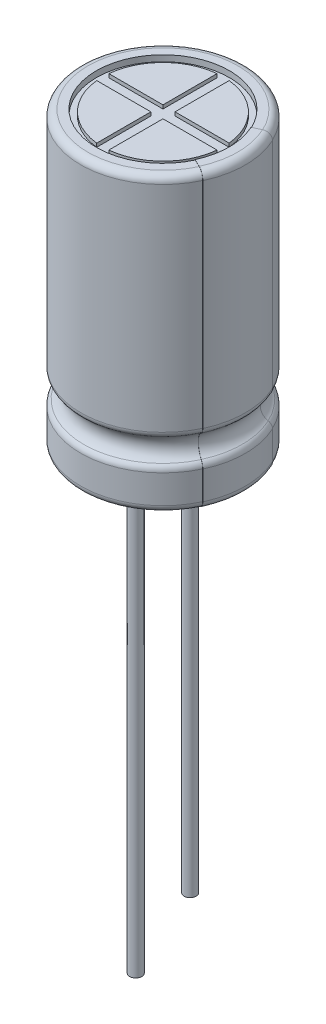
from build123d import *

# Parameters (mm, degrees)
BOSS_EXTRUDE1_DEPTH      = 0.15
BOSS_EXTRUDE1_2_DEPTH    = 0.15
BOSS_EXTRUDE1_3_DEPTH    = 0.15
BOSS_EXTRUDE1_4_DEPTH    = 0.15
SKETCH3_R                = 1.8
SKETCH3_RX               = 1.67
SKETCH3_RY               = 0.9
BOSS_EXTRUDE2_DEPTH      = 0.6
REVOLVE3_ANGLE           = 25
REVOLVE3_OTHER_WAY_ANGLE = 25
SKETCH7_R                = 0.25
BOSS_EXTRUDE3_DEPTH      = 19.6
SKETCH7_4_R              = 0.25
BOSS_EXTRUDE4_DEPTH      = 15.6


with BuildPart() as part:
    # Sketch1 → Revolve1 (revolve)
    with BuildSketch(Plane.XY, mode=Mode.PRIVATE) as revolve1_sk:
        with BuildLine():
            Line((0, 0.6), (2.8, 0.6))
            Line((2.8, 0.6), (2.8, 0.4))
            Line((2.8, 0.4), (3.1, 0.4))
            ThreePointArc((3.1, 0.4), (3.312132034, 0.487867966), (3.4, 0.7))
            Line((3.4, 0.7), (3.4, 1.873479579))
            ThreePointArc((3.4, 1.873479579), (3.365540419, 2.013080031), (3.270078093, 2.120609995))
            ThreePointArc((3.270078093, 2.120609995), (3.0180522, 2.6), (3.270078093, 3.079390005))
            ThreePointArc((3.270078093, 3.079390005), (3.365540419, 3.186919969), (3.4, 3.326520421))
            Line((3.4, 3.326520421), (3.4, 12.2))
            ThreePointArc((3.4, 12.2), (3.312132034, 12.412132034), (3.1, 12.5))
            Line((3.1, 12.5), (2.75, 12.5))
            Line((2.75, 12.5), (2.75, 12.25))
            Line((2.75, 12.25), (0, 12.25))
            Line((0, 12.25), (0, 0.6))
        make_face()
    revolve(revolve1_sk.sketch.rotate(Axis((0, 12.25, 0), (0, -1, 0)), 180), axis=Axis((0, 12.25, 0), (0, -1, 0)))



with BuildPart() as body_2:
    # Sketch2 → Boss-Extrude1 (new body)
    with BuildSketch(Plane(origin=(0, 12.25, 0), x_dir=(1, 0, 0), z_dir=(0, 1, 0))):
        with BuildLine():
            Line((-0.25, 0.25), (-0.25, 2.487468593))
            ThreePointArc((-0.25, 2.487468593), (-1.767766953, 1.767766953), (-2.487468593, 0.25))
            Line((-2.487468593, 0.25), (-0.25, 0.25))
        make_face()
    extrude(amount=BOSS_EXTRUDE1_DEPTH)


with BuildPart() as body_3:
    # Sketch2 → Boss-Extrude1 2 (new body)
    with BuildSketch(Plane(origin=(0, 12.25, 0), x_dir=(1, 0, 0), z_dir=(0, 1, 0))):
        with BuildLine():
            Line((0.25, -2.487468593), (0.25, -0.25))
            Line((0.25, -0.25), (2.487468593, -0.25))
            ThreePointArc((2.487468593, -0.25), (1.767766953, -1.767766953), (0.25, -2.487468593))
        make_face()
    extrude(amount=BOSS_EXTRUDE1_2_DEPTH)


with BuildPart() as body_4:
    # Sketch2 → Boss-Extrude1 3 (new body)
    with BuildSketch(Plane(origin=(0, 12.25, 0), x_dir=(1, 0, 0), z_dir=(0, 1, 0))):
        with BuildLine():
            Line((-0.25, -2.487468593), (-0.25, -0.25))
            Line((-0.25, -0.25), (-2.487468593, -0.25))
            ThreePointArc((-2.487468593, -0.25), (-1.767766953, -1.767766953), (-0.25, -2.487468593))
        make_face()
    extrude(amount=BOSS_EXTRUDE1_3_DEPTH)


with BuildPart() as body_5:
    # Sketch2 → Boss-Extrude1 4 (new body)
    with BuildSketch(Plane(origin=(0, 12.25, 0), x_dir=(1, 0, 0), z_dir=(0, 1, 0))):
        with BuildLine():
            Line((0.25, 0.25), (0.25, 2.487468593))
            ThreePointArc((0.25, 2.487468593), (1.767766953, 1.767766953), (2.487468593, 0.25))
            Line((2.487468593, 0.25), (0.25, 0.25))
        make_face()
    extrude(amount=BOSS_EXTRUDE1_4_DEPTH)


with BuildPart() as body_6:
    # Sketch3 → Boss-Extrude2 (new body)
    with BuildSketch(Plane.XZ.offset(-0.6)):
        Circle(SKETCH3_R)
        with Locations(Location((0, 0), (0, 0, 180))):
            Ellipse(SKETCH3_RX, SKETCH3_RY, mode=Mode.SUBTRACT)
    extrude(amount=BOSS_EXTRUDE2_DEPTH)


with BuildPart() as body_7:
    # Sketch5 → Revolve3 (revolve)
    with BuildSketch(Plane.XY):
        with BuildLine():
            Line((3.41, 12.2), (3.41, 3.326520421))
            ThreePointArc((3.41, 3.326520421), (3.374391766, 3.182266621), (3.275747363, 3.071152325))
            ThreePointArc((3.275747363, 3.071152325), (3.0280522, 2.6), (3.275747363, 2.128847675))
            ThreePointArc((3.275747363, 2.128847675), (3.374391766, 2.017733379), (3.41, 1.873479579))
            Line((3.41, 1.873479579), (3.41, 0.7))
            ThreePointArc((3.41, 0.7), (3.319203102, 0.480796898), (3.1, 0.39))
            Line((3.1, 0.39), (2.790041237, 0.39))
            Line((2.790041237, 0.39), (2.739958592, 12.51))
            Line((2.739958592, 12.51), (3.1, 12.51))
            ThreePointArc((3.1, 12.51), (3.319203102, 12.419203102), (3.41, 12.2))
        make_face()
        with BuildLine():
            Line((2.75, 12.5), (3.1, 12.5))
            ThreePointArc((3.1, 12.5), (3.312132034, 12.412132034), (3.4, 12.2))
            Line((3.4, 12.2), (3.4, 3.326520421))
            ThreePointArc((3.4, 3.326520421), (3.365540419, 3.186919969), (3.270078093, 3.079390005))
            ThreePointArc((3.270078093, 3.079390005), (3.0180522, 2.6), (3.270078093, 2.120609995))
            ThreePointArc((3.270078093, 2.120609995), (3.365540419, 2.013080031), (3.4, 1.873479579))
            Line((3.4, 1.873479579), (3.4, 0.7))
            ThreePointArc((3.4, 0.7), (3.312132034, 0.487867966), (3.1, 0.4))
            Line((3.1, 0.4), (2.8, 0.4))
            Line((2.8, 0.4), (2.75, 12.5))
        make_face(mode=Mode.SUBTRACT)
    revolve(axis=Axis((0, 0, 0), (0, 1, 0)), revolution_arc=REVOLVE3_ANGLE)

    # Sketch5 → Revolve3 other way (revolve)
    with BuildSketch(Plane.XY):
        with BuildLine():
            Line((3.41, 12.2), (3.41, 3.326520421))
            ThreePointArc((3.41, 3.326520421), (3.374391766, 3.182266621), (3.275747363, 3.071152325))
            ThreePointArc((3.275747363, 3.071152325), (3.0280522, 2.6), (3.275747363, 2.128847675))
            ThreePointArc((3.275747363, 2.128847675), (3.374391766, 2.017733379), (3.41, 1.873479579))
            Line((3.41, 1.873479579), (3.41, 0.7))
            ThreePointArc((3.41, 0.7), (3.319203102, 0.480796898), (3.1, 0.39))
            Line((3.1, 0.39), (2.790041237, 0.39))
            Line((2.790041237, 0.39), (2.739958592, 12.51))
            Line((2.739958592, 12.51), (3.1, 12.51))
            ThreePointArc((3.1, 12.51), (3.319203102, 12.419203102), (3.41, 12.2))
        make_face()
        with BuildLine():
            Line((2.75, 12.5), (3.1, 12.5))
            ThreePointArc((3.1, 12.5), (3.312132034, 12.412132034), (3.4, 12.2))
            Line((3.4, 12.2), (3.4, 3.326520421))
            ThreePointArc((3.4, 3.326520421), (3.365540419, 3.186919969), (3.270078093, 3.079390005))
            ThreePointArc((3.270078093, 3.079390005), (3.0180522, 2.6), (3.270078093, 2.120609995))
            ThreePointArc((3.270078093, 2.120609995), (3.365540419, 2.013080031), (3.4, 1.873479579))
            Line((3.4, 1.873479579), (3.4, 0.7))
            ThreePointArc((3.4, 0.7), (3.312132034, 0.487867966), (3.1, 0.4))
            Line((3.1, 0.4), (2.8, 0.4))
            Line((2.8, 0.4), (2.75, 12.5))
        make_face(mode=Mode.SUBTRACT)
    revolve(axis=Axis((0, 0, 0), (0, -1, 0)), revolution_arc=REVOLVE3_OTHER_WAY_ANGLE)


with BuildPart() as part_1:
    add(part.part)

    add(body_6.part)  # Boss-Extrude3 merges body 6
    # Sketch7 → Boss-Extrude3 (add)
    with BuildSketch(Plane.XZ.offset(-0.6)):
        with Locations(Location((-1.125, 0, 0), (0, 0, 180))):
            Circle(SKETCH7_R)
    extrude(amount=BOSS_EXTRUDE3_DEPTH)

    # Sketch7_4 → Boss-Extrude4 (add)
    with BuildSketch(Plane.XZ.offset(-0.6)):
        with Locations(Location((1.125, 0, 0), (0, 0, 180))):
            Circle(SKETCH7_4_R)
    extrude(amount=BOSS_EXTRUDE4_DEPTH)


solid = Compound([body_2.part, body_3.part, body_4.part, body_5.part, body_7.part, part_1.part])
